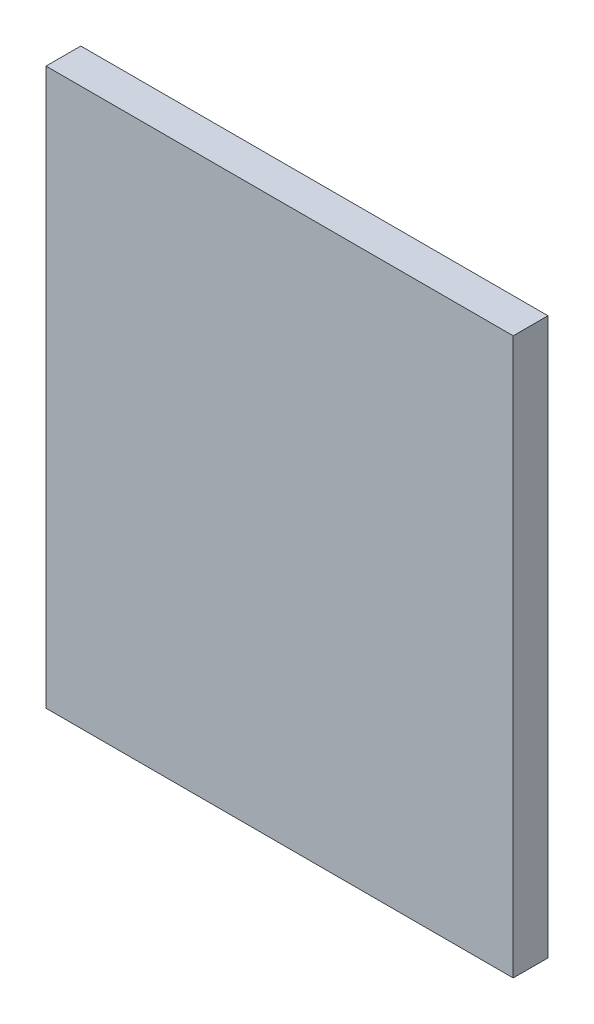
from build123d import *

# Parameters (mm, degrees)
SKETCH2_W           = 42.672
SKETCH2_H           = 50.8
BOSS_EXTRUDE1_DEPTH = 1.5875


with BuildPart() as part:
    # Sketch2 → Boss-Extrude1 (new body, symmetric)
    with BuildSketch(Plane.XY):
        Rectangle(SKETCH2_W, SKETCH2_H)
    extrude(amount=BOSS_EXTRUDE1_DEPTH, both=True)


solid = part.part
